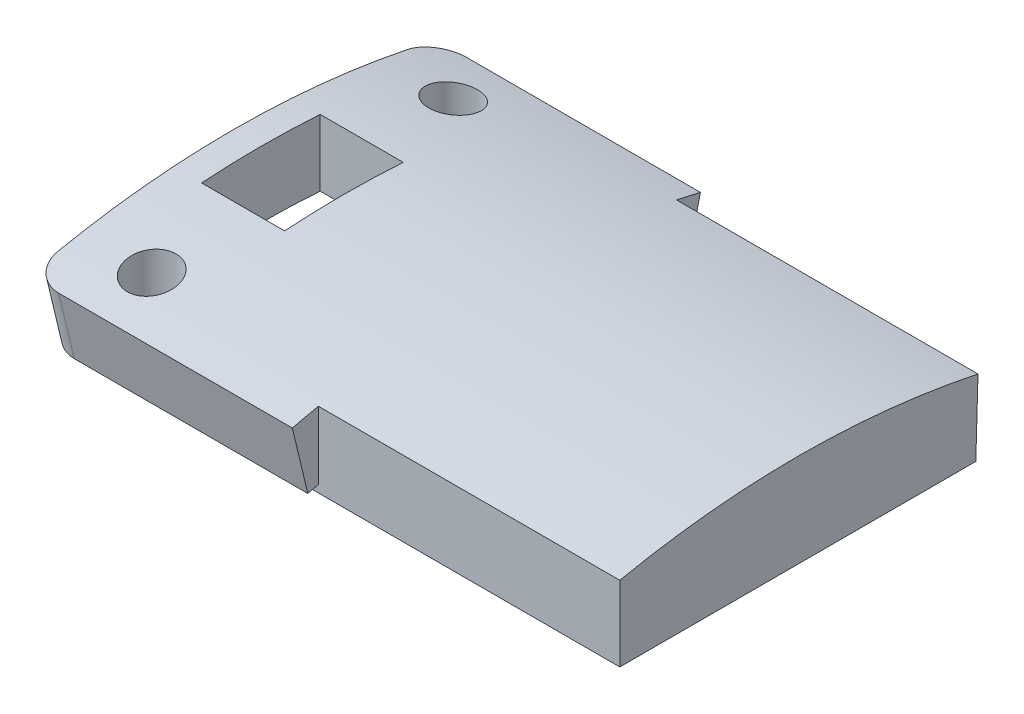
from build123d import *

# Parameters (mm, degrees)
SKETCH1_W                       = 22.225
SKETCH1_H                       = 5.588
REVOLVE1_ANGLE                  = 27
SKETCH2_W                       = 6.99999997
SKETCH2_H                       = 10.000000066
SKETCH2_R                       = 2.049999964
CUT_EXTRUDE1_DEPTH              = 22.793561204
FILLET2_R                       = 2.54
BOSS_EXTRUDE2_DEPTH             = 25.4
BOSS_EXTRUDE2_DEPTH_BACK        = 1.27
F_24_0_152_DIAMETER_HOLE1_D     = 3.8608
F_24_0_152_DIAMETER_HOLE1_DEPTH = 3.3999932
F_24_0_152_DIAMETER_HOLE1_TIP   = 1.159901339


with BuildPart() as part:
    # Sketch1 → Revolve1 (revolve, symmetric)
    with BuildSketch(Plane.XY) as revolve1_sk:
        with Locations((0, -2.794)):
            Rectangle(SKETCH1_W, SKETCH1_H)
    revolve(axis=Axis((21.580970856, -73.66, 0), (-1, 0, 0)), revolution_arc=REVOLVE1_ANGLE / 2)
    revolve(revolve1_sk.sketch, axis=Axis((21.580970856, -73.66, 0), (1, 0, 0)), revolution_arc=REVOLVE1_ANGLE / 2)

    # Sketch2 → Cut-Extrude1 (cut, through all)
    with BuildSketch(Plane(origin=(0, 0, 0), x_dir=(1, 0, 0), z_dir=(0, 1, 0))):
        with Locations((-5.231250015, 0)):
            Rectangle(SKETCH2_W, SKETCH2_H)
        with Locations((-5.231250015, 12.7)):
            Circle(SKETCH2_R)
        with Locations((-5.231250015, -12.7)):
            Circle(SKETCH2_R)
    extrude(amount=-CUT_EXTRUDE1_DEPTH, mode=Mode.SUBTRACT)

    # Fillet2
    fillet2_edges = [part.edges().sort_by_distance(p)[0] for p in [
        (-11.1125, -4.752033221, -16.543339155),
        (-11.1125, -4.752033221, 16.543339155),
    ]]
    fillet(fillet2_edges, radius=FILLET2_R)

    # Sketch8 → Boss-Extrude2 (add, two sides: drawn at the far end of the back side and taken through both)
    with BuildSketch(Plane(origin=(11.1125, 0, 0), x_dir=(0, 0, -1), z_dir=(1, 0, 0)).offset(-BOSS_EXTRUDE2_DEPTH_BACK)):
        with BuildLine():
            Line((-15, -7.874), (15, -7.874))
            Line((15, -7.874), (15.184616566, -1.5821045))
            ThreePointArc((15.184616566, -1.5821045), (0.094309083, -6.0373e-05), (-15, -1.543458208))
            Line((-15, -1.543458208), (-15, -7.874))
        make_face()
    extrude(amount=BOSS_EXTRUDE2_DEPTH + BOSS_EXTRUDE2_DEPTH_BACK)

    # 24 _0.152_ Diameter Hole1
    with Locations(Plane(origin=(0, -7.874, 0), x_dir=(-1, 0, 0), z_dir=(0, -1, 0))):
        with Locations((-32.26874997, 11.5), (-32.26874997, -11.5)):
            Hole(F_24_0_152_DIAMETER_HOLE1_D / 2, depth=F_24_0_152_DIAMETER_HOLE1_DEPTH)
            with Locations((0, 0, -(F_24_0_152_DIAMETER_HOLE1_DEPTH + F_24_0_152_DIAMETER_HOLE1_TIP / 2))):  # 118° drill point
                Cone(0, F_24_0_152_DIAMETER_HOLE1_D / 2, F_24_0_152_DIAMETER_HOLE1_TIP, mode=Mode.SUBTRACT)


solid = part.part
